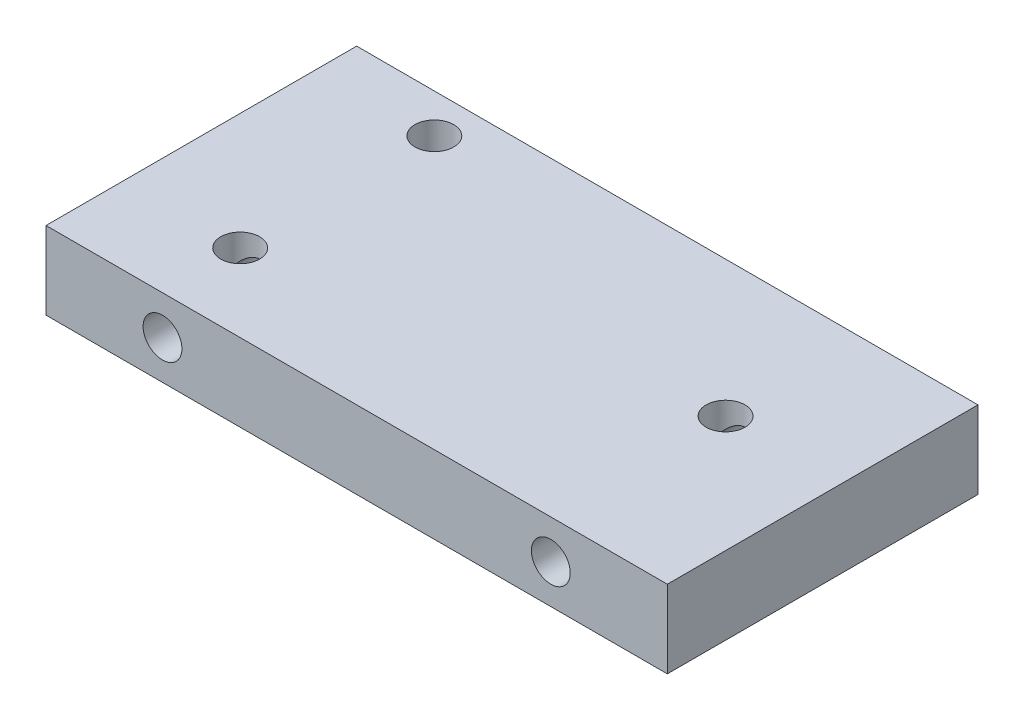
from build123d import *

# Parameters (mm, degrees)
SKETCH1_W           = 200
SKETCH1_H           = 100
BOSS_EXTRUDE1_DEPTH = 25
SKETCH2_R           = 6.25
CUT_EXTRUDE1_DEPTH  = 87.5
SKETCH3_R           = 6.25
CUT_EXTRUDE2_DEPTH  = 18.75


with BuildPart() as part:
    # Sketch1 → Boss-Extrude1 (new body)
    with BuildSketch(Plane(origin=(0, 0, 0), x_dir=(1, 0, 0), z_dir=(0, 1, 0))):
        with Locations((17.047695894, 11.5815341)):
            Rectangle(SKETCH1_W, SKETCH1_H)
    extrude(amount=BOSS_EXTRUDE1_DEPTH)

    # Sketch2 → Cut-Extrude1 (cut)
    with BuildSketch(Plane.XY.offset(38.4184659)):
        with Locations((-45.452304106, 12.5)):
            Circle(SKETCH2_R)
        with Locations((79.547695894, 12.5)):
            Circle(SKETCH2_R)
    extrude(amount=-CUT_EXTRUDE1_DEPTH, mode=Mode.SUBTRACT)

    # Sketch3 → Cut-Extrude2 (cut)
    with BuildSketch(Plane(origin=(0, 25, 0), x_dir=(1, 0, 0), z_dir=(0, 1, 0))):
        with Locations(Location((-45.452304106, -13.4184659, 0), (0, 0, 270))):
            Circle(SKETCH3_R)
        with Locations(Location((-45.452304106, 49.0815341, 0), (0, 0, 270))):
            Circle(SKETCH3_R)
        with Locations(Location((79.547695894, 17.8315341, 0), (0, 0, 270))):
            Circle(SKETCH3_R)
    extrude(amount=-CUT_EXTRUDE2_DEPTH, mode=Mode.SUBTRACT)


solid = part.part
